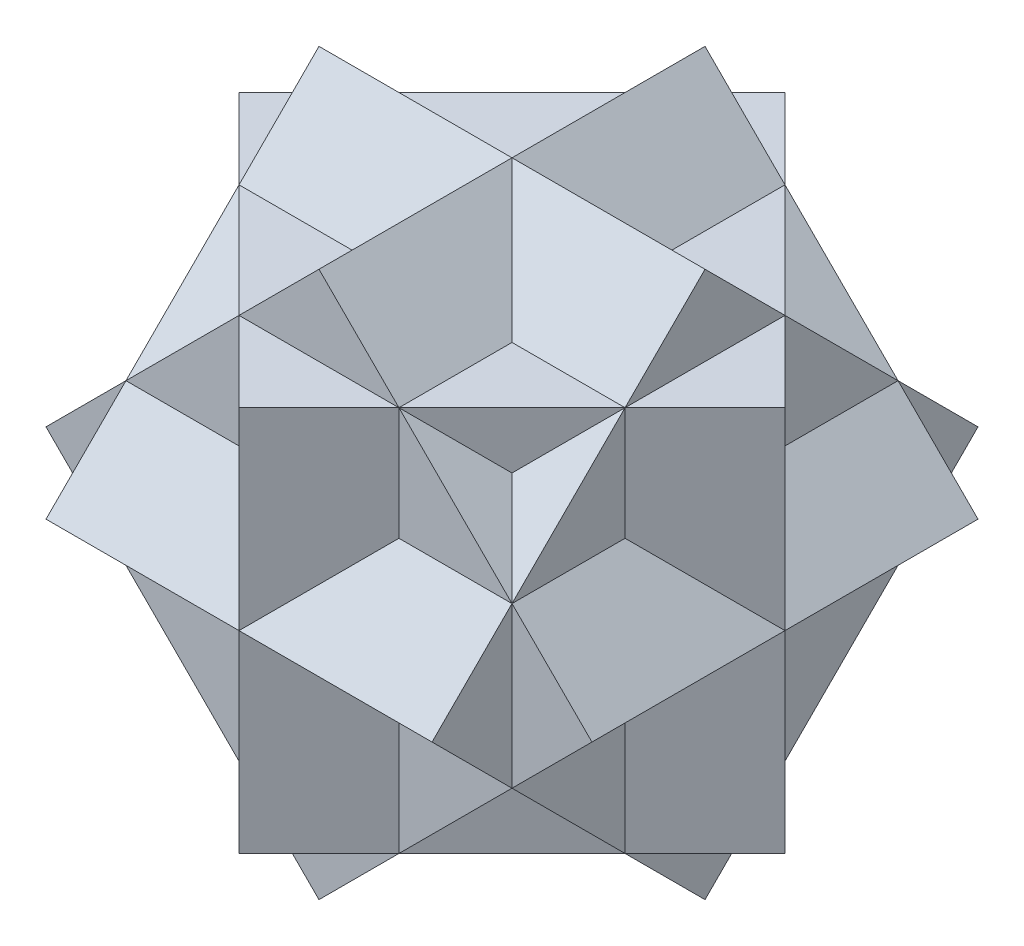
from build123d import *

# Parameters (mm, degrees)
BOSS_EXTRUDE1_DEPTH = 108.204878078
BOSS_EXTRUDE2_DEPTH = 108.204878078
BOSS_EXTRUDE3_DEPTH = 108.204878078


with BuildPart() as part:
    # Sketch3 → Boss-Extrude1 (new body, symmetric)
    with BuildSketch(Plane.XY):
        Polygon((-153.024806093, 0), (0, 153.024806093), (153.024806093, 0), (0, -153.024806093), align=None)
    extrude(amount=BOSS_EXTRUDE1_DEPTH, both=True)

    # Sketch4 → Boss-Extrude2 (add, symmetric)
    with BuildSketch(Plane(origin=(0, 0, 0), x_dir=(1, 0, 0), z_dir=(0, 1, 0))):
        Polygon((-153.024806093, 0), (0, 153.024806093), (153.024806093, 0), (0, -153.024806093), align=None)
    extrude(amount=BOSS_EXTRUDE2_DEPTH, both=True)

    # Sketch5 → Boss-Extrude3 (add, symmetric)
    with BuildSketch(Plane(origin=(0, 0, 0), x_dir=(0, 0, -1), z_dir=(1, 0, 0))):
        Polygon((-153.024806093, 0), (0, 153.024806093), (153.024806093, 0), (0, -153.024806093), align=None)
    extrude(amount=BOSS_EXTRUDE3_DEPTH, both=True)


solid = part.part
